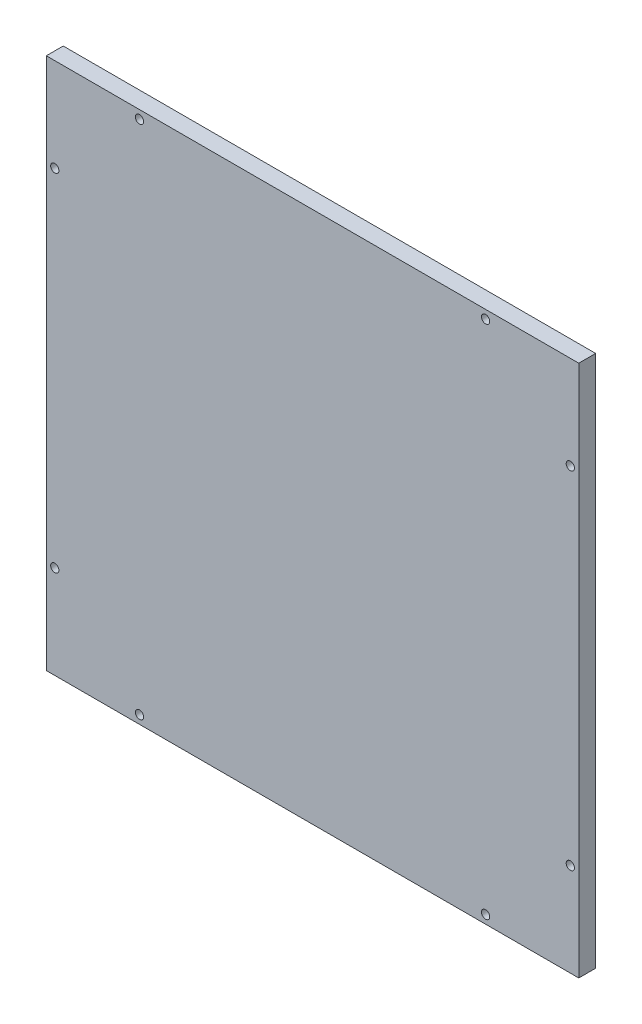
from build123d import *

# Parameters (mm, degrees)
SKETCH1_W           = 200
SKETCH1_H           = 200
BOSS_EXTRUDE1_DEPTH = 6.35
SKETCH2_R           = 1.55
CUT_EXTRUDE1_DEPTH  = 7.35


with BuildPart() as part:
    # Sketch1 → Boss-Extrude1 (new body)
    with BuildSketch(Plane.XY):
        Rectangle(SKETCH1_W, SKETCH1_H)
    extrude(amount=BOSS_EXTRUDE1_DEPTH)

    # Sketch2 → Cut-Extrude1 (cut, through all)
    with BuildSketch(Plane.XY.offset(6.35)):
        with Locations((-65, 96.825)):
            Circle(SKETCH2_R)
        with Locations((65, 96.825)):
            Circle(SKETCH2_R)
        with Locations((65, -96.825)):
            Circle(SKETCH2_R)
        with Locations((-65, -96.825)):
            Circle(SKETCH2_R)
        with Locations((96.825, 65)):
            Circle(SKETCH2_R)
        with Locations((96.825, -65)):
            Circle(SKETCH2_R)
        with Locations((-96.825, -65)):
            Circle(SKETCH2_R)
        with Locations((-96.825, 65)):
            Circle(SKETCH2_R)
    extrude(amount=-CUT_EXTRUDE1_DEPTH, mode=Mode.SUBTRACT)


solid = part.part
